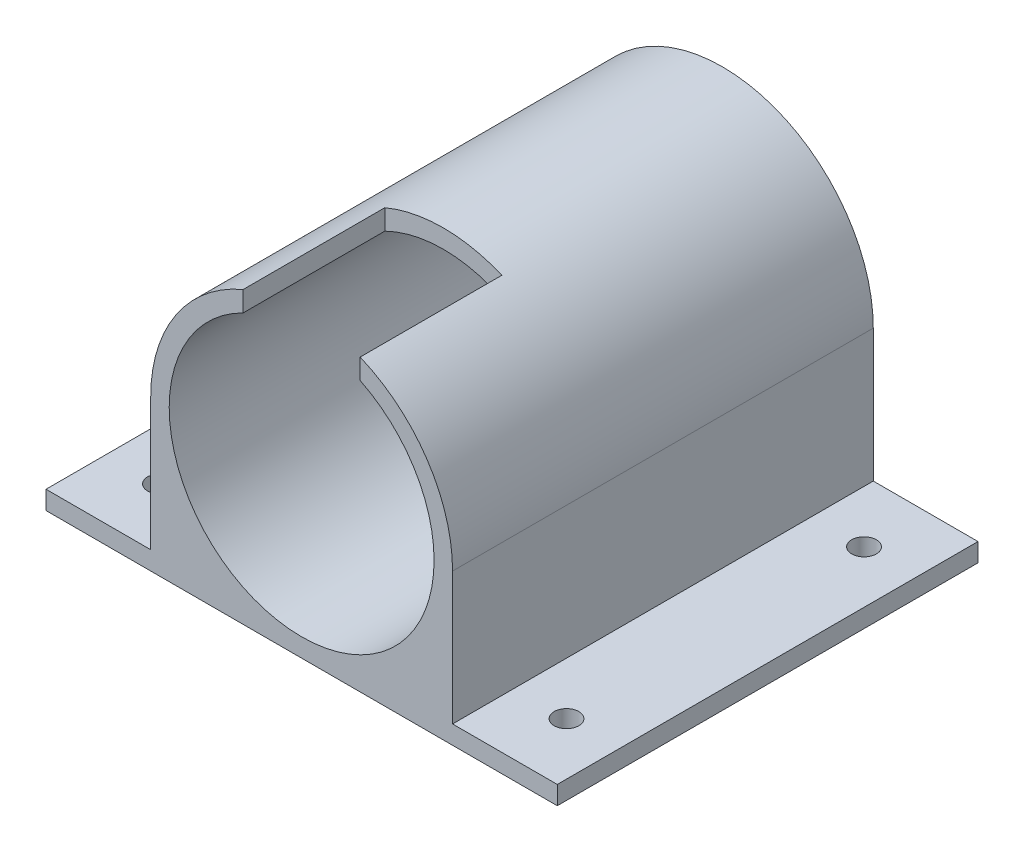
from build123d import *

# Parameters (mm, degrees)
ESQUISSE1_R             = 24.5
ESQUISSE1_R_2           = 21.5
BOSS_EXTRU_1_DEPTH      = 65.3
ESQUISSE2_R             = 21.5
ESQUISSE2_R_2           = 14.5
BOSS_EXTRU_2_DEPTH      = 3
ESQUISSE3_R             = 1.65
ENL_V_MAT_EXTRU_1_DEPTH = 3
ESQUISSE4_W             = 19
ESQUISSE4_H             = 5.738367338
ENL_V_MAT_EXTRU_2_DEPTH = 23
ESQUISSE5_W             = 68.3
ESQUISSE5_H             = 3
BOSS_EXTRU_3_DEPTH      = 17
ESQUISSE6_W             = 68.3
ESQUISSE6_H             = 3
BOSS_EXTRU_4_DEPTH      = 17
ESQUISSE7_R             = 2
ENL_V_MAT_EXTRU_3_DEPTH = 10
ESQUISSE9_R             = 2
ENL_V_MAT_EXTRU_4_DEPTH = 10


with BuildPart() as part:
    # Esquisse1 → Boss.-Extru.1 (new body)
    with BuildSketch(Plane.XY):
        Circle(ESQUISSE1_R)
        Circle(ESQUISSE1_R_2, mode=Mode.SUBTRACT)
        with BuildLine():
            Line((-24.5, 0), (-24.5, -24.5))
            Line((-24.5, -24.5), (-6e-09, -24.5))
            ThreePointArc((-6e-09, -24.5), (-17.324116141, -17.324116137), (-24.5, 0))
        make_face()
        with BuildLine():
            ThreePointArc((24.5, 0), (17.324116137, -17.324116141), (-6e-09, -24.5))
            Line((-6e-09, -24.5), (24.5, -24.5))
            Line((24.5, -24.5), (24.5, 0))
        make_face()
    extrude(amount=BOSS_EXTRU_1_DEPTH)

    # Esquisse2 → Boss.-Extru.2 (add)
    with BuildSketch(Plane(origin=(0, 0, 0), x_dir=(-1, 0, 0), z_dir=(0, 0, -1))):
        with BuildLine():
            ThreePointArc((24.5, 0), (0, 24.5), (-24.5, 0))
            ThreePointArc((-24.5, 0), (-17.324116141, -17.324116137), (-6e-09, -24.5))
            ThreePointArc((-6e-09, -24.5), (17.324116137, -17.324116141), (24.5, 0))
        make_face()
        with Locations(Location((0, 0, 0), (0, 0, 180))):
            Circle(ESQUISSE2_R, mode=Mode.SUBTRACT)
        with Locations(Location((0, 0, 0), (0, 0, 180))):
            Circle(ESQUISSE2_R)
        Circle(ESQUISSE2_R_2, mode=Mode.SUBTRACT)
        with BuildLine():
            ThreePointArc((-6e-09, -24.5), (-17.324116141, -17.324116137), (-24.5, 0))
            Line((-24.5, 0), (-24.5, -24.5))
            Line((-24.5, -24.5), (-6e-09, -24.5))
        make_face()
        with BuildLine():
            Line((24.5, -24.5), (24.5, 0))
            ThreePointArc((24.5, 0), (17.324116137, -17.324116141), (-6e-09, -24.5))
            Line((-6e-09, -24.5), (24.5, -24.5))
        make_face()
    extrude(amount=BOSS_EXTRU_2_DEPTH)

    # Esquisse3 → Enlèv. mat.-Extru.1 (cut)
    with BuildSketch(Plane(origin=(0, 0, -3), x_dir=(-1, 0, 0), z_dir=(0, 0, -1))):
        with Locations((-17.5, 0)):
            Circle(ESQUISSE3_R)
        with Locations((17.5, 0)):
            Circle(ESQUISSE3_R)
        with Locations((0, 17.5)):
            Circle(ESQUISSE3_R)
        with Locations((0, -17.5)):
            Circle(ESQUISSE3_R)
    extrude(amount=-ENL_V_MAT_EXTRU_1_DEPTH, mode=Mode.SUBTRACT)

    # Esquisse4 → Enlèv. mat.-Extru.2 (cut)
    with BuildSketch(Plane.XY.offset(65.3)):
        with Locations((0, 22.156485191)):
            Rectangle(ESQUISSE4_W, ESQUISSE4_H)
    extrude(amount=-ENL_V_MAT_EXTRU_2_DEPTH, mode=Mode.SUBTRACT)

    # Esquisse5 → Boss.-Extru.3 (add)
    with BuildSketch(Plane.ZY.offset(24.5)):
        with Locations((31.15, -23)):
            Rectangle(ESQUISSE5_W, ESQUISSE5_H)
    extrude(amount=BOSS_EXTRU_3_DEPTH)

    # Esquisse6 → Boss.-Extru.4 (add)
    with BuildSketch(Plane(origin=(24.5, 0, 0), x_dir=(0, 0, -1), z_dir=(1, 0, 0))):
        with Locations((-31.15, -23)):
            Rectangle(ESQUISSE6_W, ESQUISSE6_H)
    extrude(amount=BOSS_EXTRU_4_DEPTH)

    # Esquisse7 → Enlèv. mat.-Extru.3 (cut)
    with BuildSketch(Plane(origin=(0, -21.5, 0), x_dir=(1, 0, 0), z_dir=(0, 1, 0))):
        with Locations(Location((-33, -7, 0), (0, 0, 270))):
            Circle(ESQUISSE7_R)
        with Locations(Location((-33, -55.3, 0), (0, 0, 270))):
            Circle(ESQUISSE7_R)
    extrude(amount=-ENL_V_MAT_EXTRU_3_DEPTH, mode=Mode.SUBTRACT)

    # Esquisse9 → Enlèv. mat.-Extru.4 (cut)
    with BuildSketch(Plane(origin=(0, -21.5, 0), x_dir=(1, 0, 0), z_dir=(0, 1, 0))):
        with Locations(Location((33, -7, 0), (0, 0, 270))):
            Circle(ESQUISSE9_R)
        with Locations(Location((33, -55.3, 0), (0, 0, 270))):
            Circle(ESQUISSE9_R)
    extrude(amount=-ENL_V_MAT_EXTRU_4_DEPTH, mode=Mode.SUBTRACT)


solid = part.part
